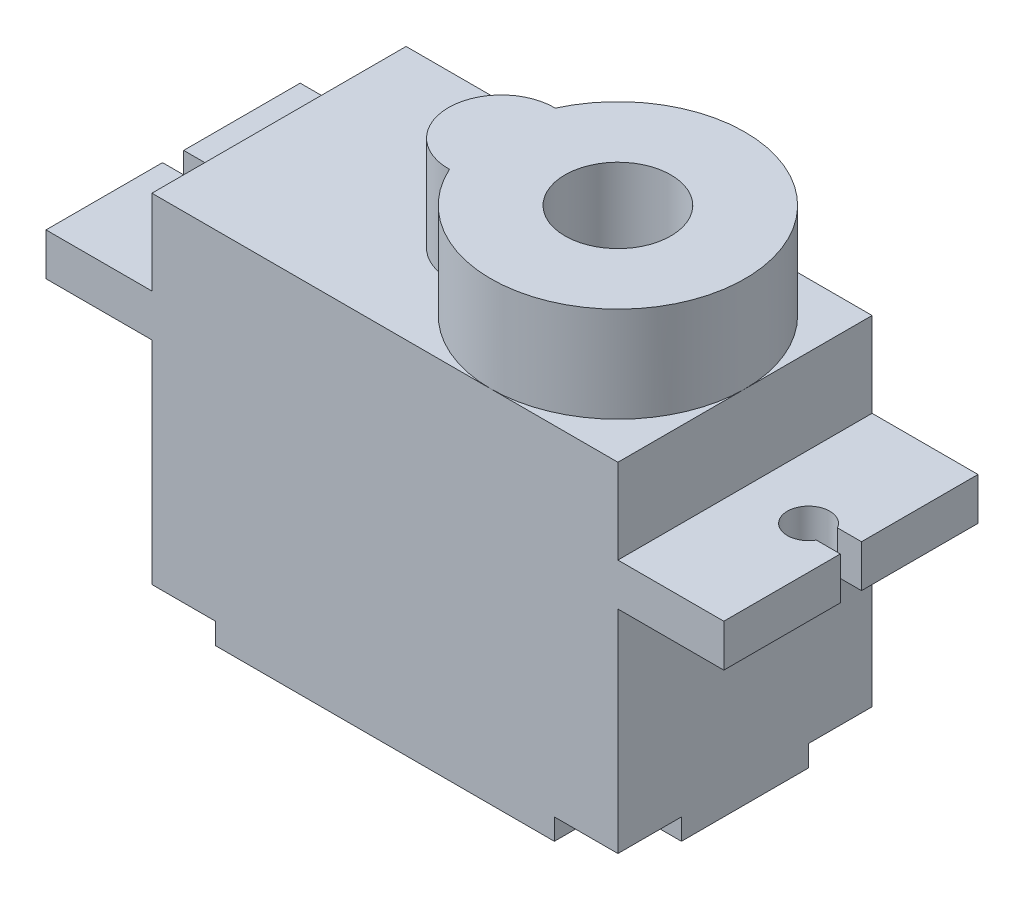
from build123d import *

# Parameters (mm, degrees)
CROQUIS1_W              = 22
CROQUIS1_H              = 12
SALIENTE_EXTRUIR1_DEPTH = 11
CROQUIS3_W              = 10
CROQUIS3_H              = 12
SALIENTE_EXTRUIR2_DEPTH = 2
CROQUIS4_W              = 12
CROQUIS4_H              = 12
SALIENTE_EXTRUIR3_DEPTH = 6
CORTAR_EXTRUIR1_DEPTH   = 2
CROQUIS6_W              = 5
CROQUIS6_H              = 12
SALIENTE_EXTRUIR4_DEPTH = 4
CORTAR_EXTRUIR2_DEPTH   = 4
CROQUIS8_R              = 6
SALIENTE_EXTRUIR5_DEPTH = 4.5
SALIENTE_EXTRUIR6_DEPTH = 4.5
CROQUIS10_W             = 3
CROQUIS10_H             = 3
CORTAR_EXTRUIR3_DEPTH   = 1
REDONDEO1_R             = 1.5
CROQUIS11_W             = 3
CROQUIS11_H             = 3
CORTAR_EXTRUIR4_DEPTH   = 1
REDONDEO3_R             = 1.5
CROQUIS12_R             = 1
CORTAR_EXTRUIR5_DEPTH   = 3
CROQUIS13_R             = 2.5
CORTAR_EXTRUIR6_DEPTH   = 5


with BuildPart() as part:
    # Croquis1 → Saliente-Extruir1 (new body)
    with BuildSketch(Plane(origin=(0, 0, 0), x_dir=(1, 0, 0), z_dir=(0, 1, 0))):
        Rectangle(CROQUIS1_W, CROQUIS1_H)
    extrude(amount=SALIENTE_EXTRUIR1_DEPTH)

    # Croquis3 → Saliente-Extruir2 (add)
    with BuildSketch(Plane(origin=(0, 11, 0), x_dir=(1, 0, 0), z_dir=(0, 1, 0))):
        with Locations((-11, 0)):
            Rectangle(CROQUIS3_W, CROQUIS3_H)
        with Locations((11, 0)):
            Rectangle(CROQUIS3_W, CROQUIS3_H)
    extrude(amount=SALIENTE_EXTRUIR2_DEPTH)

    # Croquis4 → Saliente-Extruir3 (add)
    with BuildSketch(Plane(origin=(0, 11, 0), x_dir=(1, 0, 0), z_dir=(0, 1, 0))):
        Rectangle(CROQUIS4_W, CROQUIS4_H)
    extrude(amount=SALIENTE_EXTRUIR3_DEPTH)

    # Croquis5 → Cortar-Extruir1 (cut)
    with BuildSketch(Plane(origin=(0, 13, 0), x_dir=(1, 0, 0), z_dir=(0, 1, 0))):
        with BuildLine():
            Line((-16, 0), (-16, 0.5))
            Line((-16, 0.5), (-15, 0.5))
            Line((-15, 0.5), (-14.866025404, 0.5))
            ThreePointArc((-14.866025404, 0.5), (-13, 0), (-14.866025404, -0.5))
            Line((-14.866025404, -0.5), (-15, -0.5))
            Line((-15, -0.5), (-15.911665796, -0.5))
            Line((-15.911665796, -0.5), (-16, -0.5))
            Line((-16, -0.5), (-16, 0))
        make_face()
    extrude(amount=-CORTAR_EXTRUIR1_DEPTH, mode=Mode.SUBTRACT)

    # Croquis6 → Saliente-Extruir4 (add)
    with BuildSketch(Plane(origin=(0, 13, 0), x_dir=(1, 0, 0), z_dir=(0, 1, 0))):
        with Locations((-8.5, 0)):
            Rectangle(CROQUIS6_W, CROQUIS6_H)
        with Locations((8.5, 0)):
            Rectangle(CROQUIS6_W, CROQUIS6_H)
    extrude(amount=SALIENTE_EXTRUIR4_DEPTH)

    # Croquis7 → Cortar-Extruir2 (cut)
    with BuildSketch(Plane(origin=(0, 13, 0), x_dir=(1, 0, 0), z_dir=(0, 1, 0))):
        with BuildLine():
            Line((16, 0), (16, 0.5))
            Line((16, 0.5), (14.906951689, 0.5))
            Line((14.906951689, 0.5), (14.866025404, 0.5))
            ThreePointArc((14.866025404, 0.5), (13, 0), (14.866025404, -0.5))
            Line((14.866025404, -0.5), (15, -0.5))
            Line((15, -0.5), (16, -0.5))
            Line((16, -0.5), (16, 0))
        make_face()
    extrude(amount=-CORTAR_EXTRUIR2_DEPTH, mode=Mode.SUBTRACT)

    # Croquis8 → Saliente-Extruir5 (add)
    with BuildSketch(Plane(origin=(0, 17, 0), x_dir=(1, 0, 0), z_dir=(0, 1, 0))):
        with Locations((5, 0)):
            Circle(CROQUIS8_R)
    extrude(amount=SALIENTE_EXTRUIR5_DEPTH)

    # Croquis9 → Saliente-Extruir6 (add)
    with BuildSketch(Plane(origin=(0, 17, 0), x_dir=(1, 0, 0), z_dir=(0, 1, 0))):
        with BuildLine():
            ThreePointArc((-0.454545455, -2.499586743), (-1, 0), (-0.454545455, 2.499586743))
            ThreePointArc((-0.454545455, 2.499586743), (-3, 0), (-0.454545455, -2.499586743))
        make_face()
    extrude(amount=SALIENTE_EXTRUIR6_DEPTH)

    # Croquis10 → Cortar-Extruir3 (cut)
    with BuildSketch(Plane(origin=(0, 0, 0), x_dir=(-1, 0, 0), z_dir=(0, -1, 0))):
        with Locations((9.5, -4.5)):
            Rectangle(CROQUIS10_W, CROQUIS10_H)
    extrude(amount=-CORTAR_EXTRUIR3_DEPTH, mode=Mode.SUBTRACT)

    # Redondeo1
    redondeo1_edges = [part.edges().sort_by_distance(p)[0] for p in [
        (-8, 0.5, 3),
    ]]
    fillet(redondeo1_edges, radius=REDONDEO1_R)

    # Croquis11 → Cortar-Extruir4 (cut)
    with BuildSketch(Plane(origin=(0, 0, 0), x_dir=(-1, 0, 0), z_dir=(0, -1, 0))):
        with Locations((9.5, 4.5)):
            Rectangle(CROQUIS11_W, CROQUIS11_H)
        with Locations((-9.5, -4.5)):
            Rectangle(CROQUIS11_W, CROQUIS11_H)
        with Locations((-9.5, 4.5)):
            Rectangle(CROQUIS11_W, CROQUIS11_H)
    extrude(amount=-CORTAR_EXTRUIR4_DEPTH, mode=Mode.SUBTRACT)

    # Redondeo3
    redondeo3_edges = [part.edges().sort_by_distance(p)[0] for p in [
        (-8, 0.5, -3),
        (8, 0.5, 3),
        (8, 0.5, -3),
    ]]
    fillet(redondeo3_edges, radius=REDONDEO3_R)

    # Croquis12 → Cortar-Extruir5 (cut)
    with BuildSketch(Plane(origin=(0, 1, 0), x_dir=(-1, 0, 0), z_dir=(0, -1, 0))):
        with Locations((9.75, -4.75)):
            Circle(CROQUIS12_R)
        with Locations((9.75, 4.75)):
            Circle(CROQUIS12_R)
        with Locations((-9.75, -4.75)):
            Circle(CROQUIS12_R)
        with Locations((-9.75, 4.75)):
            Circle(CROQUIS12_R)
    extrude(amount=-CORTAR_EXTRUIR5_DEPTH, mode=Mode.SUBTRACT)

    # Croquis13 → Cortar-Extruir6 (cut)
    with BuildSketch(Plane(origin=(0, 21.5, 0), x_dir=(1, 0, 0), z_dir=(0, 1, 0))):
        with Locations((5, 0)):
            Circle(CROQUIS13_R)
    extrude(amount=-CORTAR_EXTRUIR6_DEPTH, mode=Mode.SUBTRACT)


solid = part.part
